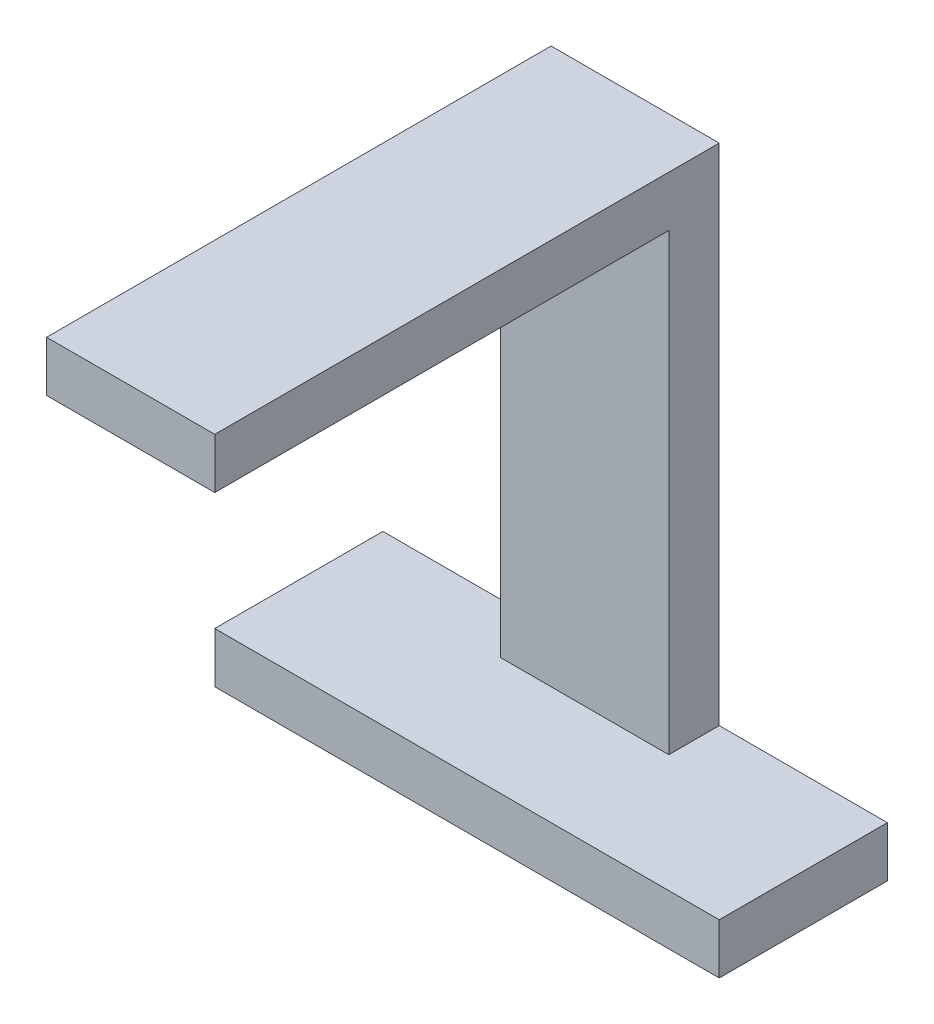
from build123d import *

# Parameters (mm, degrees)
EXTRUDE_2_DEPTH = 10
EXTRUDE_3_DEPTH = 3


with BuildPart() as part:
    # 草图2 → 凸台-拉伸2 (new body)
    with BuildSketch(Plane(origin=(0, 0, 0), x_dir=(0, 0, -1), z_dir=(1, 0, 0))):
        Polygon((-15.350951503, 50.748946778), (14.649048497, 50.748946778), (14.649048497, 20.748946778), (11.649048497, 20.748946778), (11.649048497, 47.75022668), (-15.350951503, 47.75022668), align=None)
    extrude(amount=EXTRUDE_2_DEPTH)

    # 草图4 → 凸台-拉伸3 (add)
    with BuildSketch(Plane.XZ.offset(-20.748946778)):
        Polygon((10, -14.649048497), (-10, -14.649048497), (-10, -4.649048497), (10, -4.649048497), (20, -4.649048497), (20, -14.649048497), align=None)
    extrude(amount=EXTRUDE_3_DEPTH)


solid = part.part
